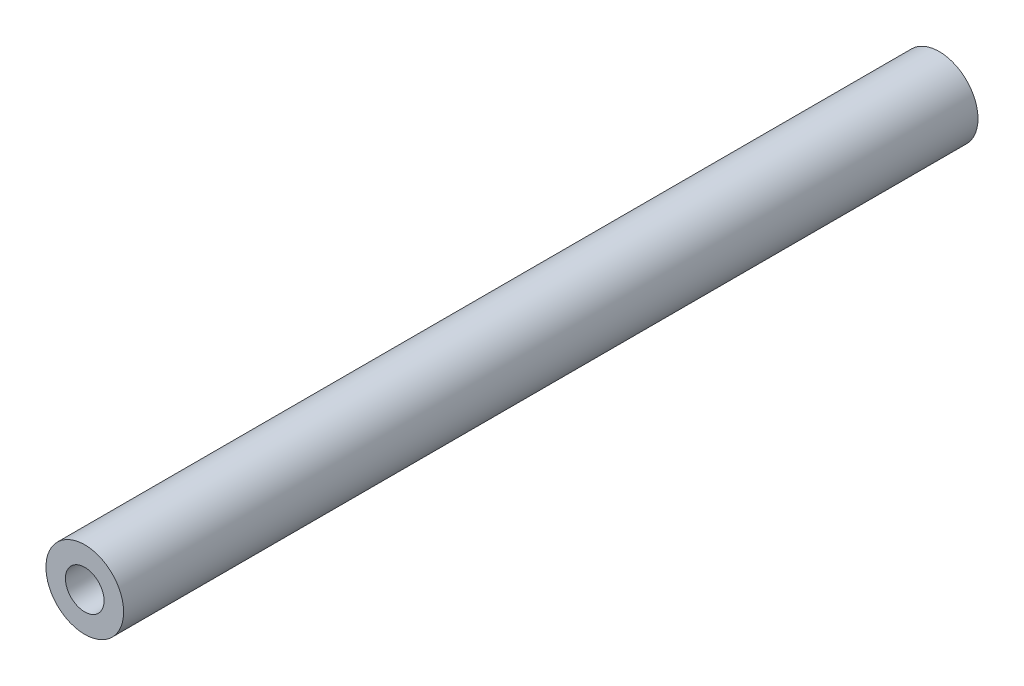
from build123d import *

# Parameters (mm, degrees)
SKETCH2_R           = 25.394730732
SKETCH2_R_2         = 12.638507994
BOSS_EXTRUDE1_DEPTH = 558.8


with BuildPart() as part:
    # Sketch2 → Boss-Extrude1 (new body)
    with BuildSketch(Plane.XY):
        Circle(SKETCH2_R)
        Circle(SKETCH2_R_2, mode=Mode.SUBTRACT)
    extrude(amount=BOSS_EXTRUDE1_DEPTH)


solid = part.part
